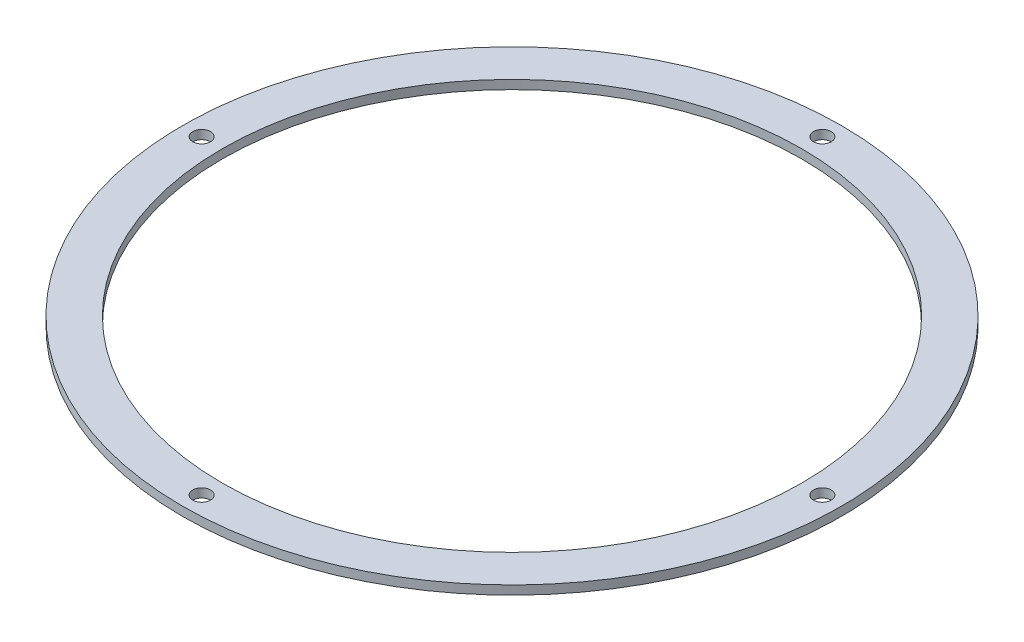
from build123d import *

# Parameters (mm, degrees)
SKETCH1_R           = 111.5
SKETCH1_R_2         = 98
BOSS_EXTRUDE1_DEPTH = 3
SKETCH2_R           = 3
CUT_EXTRUDE1_DEPTH  = 4


with BuildPart() as part:
    # Sketch1 → Boss-Extrude1 (new body)
    with BuildSketch(Plane(origin=(0, 0, 0), x_dir=(1, 0, 0), z_dir=(0, 1, 0))):
        Circle(SKETCH1_R)
        Circle(SKETCH1_R_2, mode=Mode.SUBTRACT)
    extrude(amount=BOSS_EXTRUDE1_DEPTH)

    # Sketch2 → Cut-Extrude1 (cut, through all)
    with BuildSketch(Plane(origin=(0, 3, 0), x_dir=(1, 0, 0), z_dir=(0, 1, 0))):
        with Locations((0, 105)):
            Circle(SKETCH2_R)
        with Locations((105, 0)):
            Circle(SKETCH2_R)
        with Locations((0, -105)):
            Circle(SKETCH2_R)
        with Locations((-105, 0)):
            Circle(SKETCH2_R)
    extrude(amount=-CUT_EXTRUDE1_DEPTH, mode=Mode.SUBTRACT)


solid = part.part
